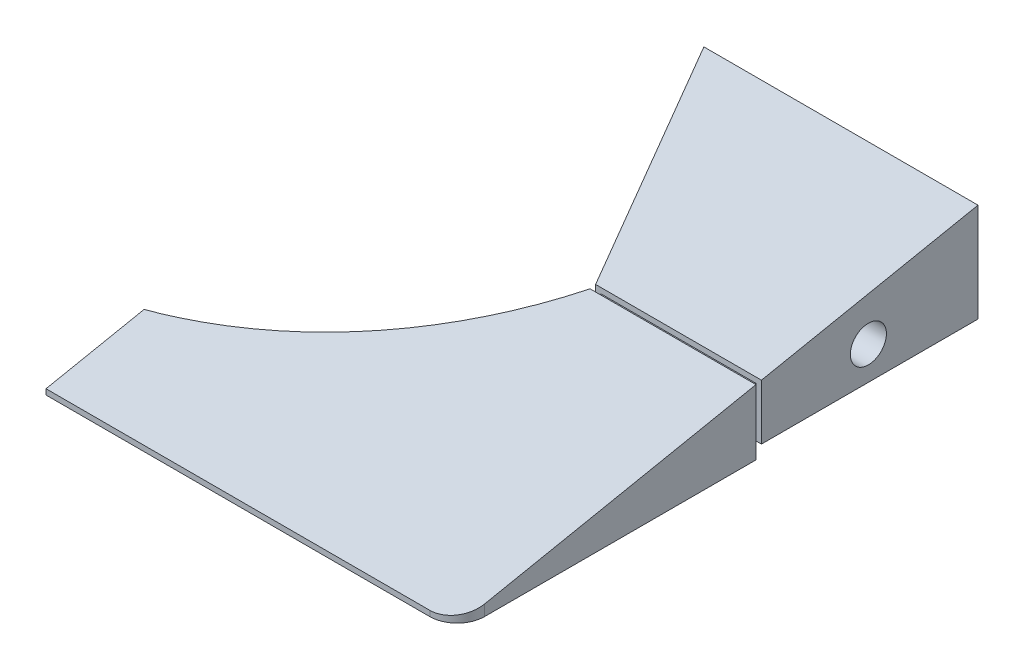
from build123d import *

# Parameters (mm, degrees)
ESBO_O1_W                                      = 130
ESBO_O1_H                                      = 20
RESSALTO_EXTRUS_O1_DEPTH                       = 95
CORTE_EXTRUS_O2_REACH                          = 22
CORTE_EXTRUS_O3_DEPTH                          = 1
CORTE_EXTRUS_O3_DEPTH_BACK                     = 131
BROCA_DE_ROSQUEAR_DE_CANO_PARA_TARRAXA_D_D     = 6.579997
BROCA_DE_ROSQUEAR_DE_CANO_PARA_TARRAXA_D_DEPTH = 10
BROCA_DE_ROSQUEAR_DE_CANO_PARA_TARRAXA_D_TIP   = 1.976830535
BROCA_DE_ROSQUEAR_DE_CANO_PARA_TARRA_2_D       = 6.579997
BROCA_DE_ROSQUEAR_DE_CANO_PARA_TARRA_2_DEPTH   = 10
BROCA_DE_ROSQUEAR_DE_CANO_PARA_TARRA_2_TIP     = 1.976830535
FILETE2_R                                      = 5
CORTE_EXTRUS_O5_DEPTH                          = 131
RESSALTO_EXTRUS_O2_REACH                       = 57.5
ESBO_O15_W                                     = 28.25
ESBO_O15_H                                     = 8.1
ESBO_O16_W                                     = 50
ESBO_O16_H                                     = 2
CORTE_EXTRUS_O6_DEPTH                          = 40.5
CORTE_EXTRUS_O7_REACH                          = 21.612
ESBO_O17_W                                     = 55
ESBO_O17_H                                     = 19.621819015


with BuildPart() as part:
    # Esboço1 → Ressalto-extrusão1 (new body)
    with BuildSketch(Plane.XY):
        Rectangle(ESBO_O1_W, ESBO_O1_H)
    extrude(amount=RESSALTO_EXTRUS_O1_DEPTH)

    # Esboço2 → Corte-extrusão2 (cut, up to next)
    with BuildSketch(Plane(origin=(0, 10, 0), x_dir=(1, 0, 0), z_dir=(0, 1, 0)), mode=Mode.PRIVATE) as corte_extrus_o2_sk1:
        with BuildLine():
            Line((15, 0), (-65, 0))
            Line((-65, 0), (-65, -80))
            Line((-65, -80), (-30.4, -80))
            ThreePointArc((-30.4, -80), (7.930824636, -69.206398281), (35, -40))
            Line((35, -40), (15, 0))
        make_face()
    corte_extrus_o2_tool1 = extrude(corte_extrus_o2_sk1.sketch, amount=-CORTE_EXTRUS_O2_REACH, mode=Mode.PRIVATE) & part.part
    add(corte_extrus_o2_tool1.solids().sort_by_distance((-21.312918, 10, 38.404489))[0], mode=Mode.SUBTRACT)

    # Esboço3 → Corte-extrusão3 (cut, two sides)
    with BuildSketch(Plane(origin=(65, 0, 0), x_dir=(0, 0, -1), z_dir=(1, 0, 0))) as corte_extrus_o3_sk:
        Polygon((200.200134404, 50.040026881), (0, 10), (-95, -9), (-295.200134404, -49.040026881), (-375.280188165, 351.360241926), (120.120080642, 450.440295688), align=None)
    extrude(amount=CORTE_EXTRUS_O3_DEPTH, mode=Mode.SUBTRACT)
    extrude(corte_extrus_o3_sk.sketch, amount=-CORTE_EXTRUS_O3_DEPTH_BACK, mode=Mode.SUBTRACT)

    # Broca de rosquear de cano para tarraxa d
    with Locations(Plane(origin=(65, 0, 0), x_dir=(0, 0, -1), z_dir=(1, 0, 0))):
        with Locations((-20, -1.945)):
            Hole(BROCA_DE_ROSQUEAR_DE_CANO_PARA_TARRAXA_D_D / 2, depth=BROCA_DE_ROSQUEAR_DE_CANO_PARA_TARRAXA_D_DEPTH)
            with Locations((0, 0, -(BROCA_DE_ROSQUEAR_DE_CANO_PARA_TARRAXA_D_DEPTH + BROCA_DE_ROSQUEAR_DE_CANO_PARA_TARRAXA_D_TIP / 2))):  # 118° drill point
                Cone(0, BROCA_DE_ROSQUEAR_DE_CANO_PARA_TARRAXA_D_D / 2, BROCA_DE_ROSQUEAR_DE_CANO_PARA_TARRAXA_D_TIP, mode=Mode.SUBTRACT)

    # Broca de rosquear de cano para tarra 2
    with Locations(Plane(origin=(12, 0, -6), x_dir=(0.447213595, 0, 0.894427191), z_dir=(-0.894427191, 0, 0.447213595))):
        with Locations((26.708203932, -1.945)):
            Hole(BROCA_DE_ROSQUEAR_DE_CANO_PARA_TARRA_2_D / 2, depth=BROCA_DE_ROSQUEAR_DE_CANO_PARA_TARRA_2_DEPTH)
            with Locations((0, 0, -(BROCA_DE_ROSQUEAR_DE_CANO_PARA_TARRA_2_DEPTH + BROCA_DE_ROSQUEAR_DE_CANO_PARA_TARRA_2_TIP / 2))):  # 118° drill point
                Cone(0, BROCA_DE_ROSQUEAR_DE_CANO_PARA_TARRA_2_D / 2, BROCA_DE_ROSQUEAR_DE_CANO_PARA_TARRA_2_TIP, mode=Mode.SUBTRACT)

    # Filete2
    filete2_edges = [part.edges().sort_by_distance(p)[0] for p in [
        (65, -9.5, 95),
    ]]
    fillet(filete2_edges, radius=FILETE2_R)

    # Esboço14 → Corte-extrusão5 (cut, through all)
    with BuildSketch(Plane(origin=(65, 0, 0), x_dir=(0, 0, -1), z_dir=(1, 0, 0))):
        Polygon((-40.5, -10), (-39.5, -10), (-39.5, 2.1), (-40.5, 1.9), align=None)
    extrude(amount=-CORTE_EXTRUS_O5_DEPTH, mode=Mode.SUBTRACT)

    # Esboço15 → Ressalto-extrusão2 (add, up to next)
    with BuildSketch(Plane.XY.offset(39.5), mode=Mode.PRIVATE) as ressalto_extrus_o2_sk1:
        with Locations((49.875, -2.95)):
            Rectangle(ESBO_O15_W, ESBO_O15_H)
    ressalto_extrus_o2_tool1 = extrude(ressalto_extrus_o2_sk1.sketch, amount=RESSALTO_EXTRUS_O2_REACH, mode=Mode.PRIVATE) - part.part
    add(ressalto_extrus_o2_tool1.solids().sort_by_distance((49.875, -2.95, 39.5))[0])

    # Esboço16 → Corte-extrusão6 (cut)
    with BuildSketch(Plane(origin=(0, 0, 0), x_dir=(-1, 0, 0), z_dir=(0, 0, -1))):
        with Locations((-40, -9)):
            Rectangle(ESBO_O16_W, ESBO_O16_H)
    extrude(amount=-CORTE_EXTRUS_O6_DEPTH, mode=Mode.SUBTRACT)

    # Esboço17 → Corte-extrusão7 (cut, up to next)
    with BuildSketch(Plane(origin=(0, 9.615384615, 1.923076923), x_dir=(1, 0, 0), z_dir=(0, 0.980580676, 0.196116135)), mode=Mode.PRIVATE) as corte_extrus_o7_sk1:
        with Locations((-37.5, -86.4868795)):
            Rectangle(ESBO_O17_W, ESBO_O17_H)
    corte_extrus_o7_tool1 = extrude(corte_extrus_o7_sk1.sketch, amount=-CORTE_EXTRUS_O7_REACH, mode=Mode.PRIVATE) & part.part
    add(corte_extrus_o7_tool1.solids().sort_by_distance((-37.5, -7.346088, 86.73044))[0], mode=Mode.SUBTRACT)


solid = part.part
